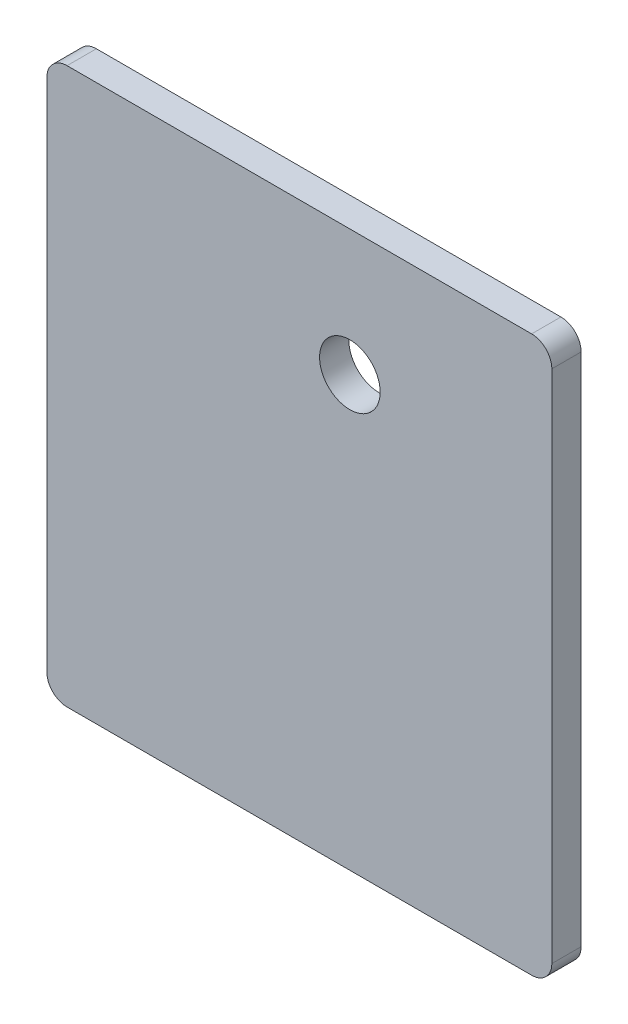
from build123d import *

# Parameters (mm, degrees)
CROQUIS1_W              = 50
CROQUIS1_H              = 55
CROQUIS1_R              = 3
SALIENTE_EXTRUIR1_DEPTH = 2.9
REDONDEO1_R             = 2
REDONDEO2_R             = 2


with BuildPart() as part:
    # Croquis1 → Saliente-Extruir1 (new body)
    with BuildSketch(Plane.XY):
        with Locations((25, 27.5)):
            Rectangle(CROQUIS1_W, CROQUIS1_H)
        with Locations((30, 42.5)):
            Circle(CROQUIS1_R, mode=Mode.SUBTRACT)
    extrude(amount=SALIENTE_EXTRUIR1_DEPTH)

    # Redondeo1
    redondeo1_edges = [part.edges().sort_by_distance(p)[0] for p in [
        (50, 0, 1.45),
        (0, 0, 1.45),
    ]]
    fillet(redondeo1_edges, radius=REDONDEO1_R)

    # Redondeo2
    redondeo2_edges = [part.edges().sort_by_distance(p)[0] for p in [
        (0, 55, 1.45),
        (50, 55, 1.45),
    ]]
    fillet(redondeo2_edges, radius=REDONDEO2_R)


solid = part.part
